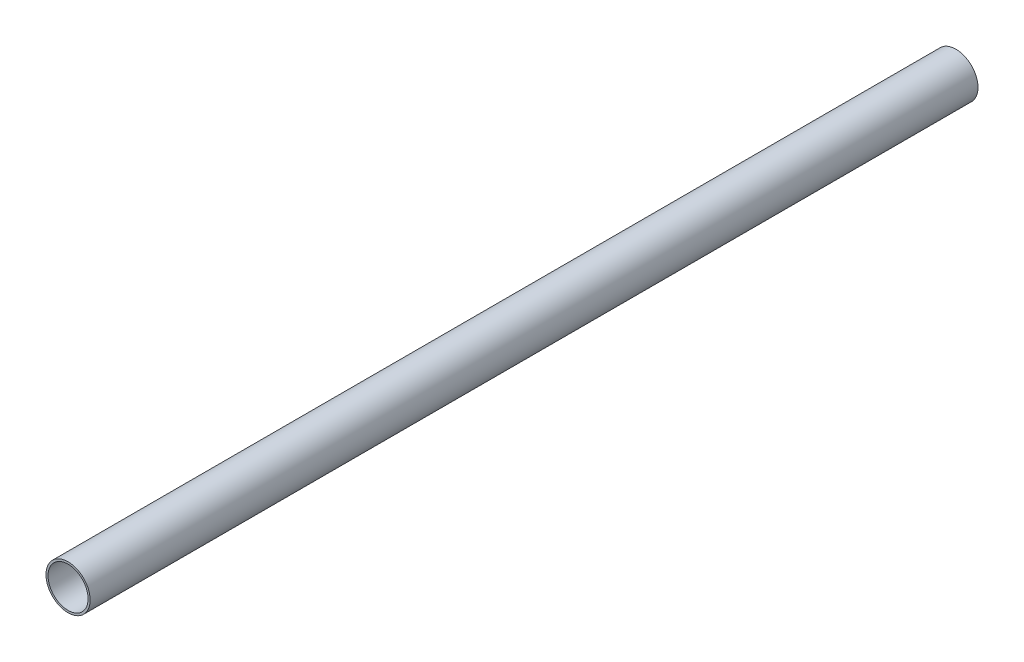
from build123d import *

# Parameters (mm, degrees)
PIPESKETCH_R    = 136.525
PIPESKETCH_R_2  = 123.825
EXTRUSION_DEPTH = 5486.4


with BuildPart() as part:
    # PipeSketch → Extrusion (new body)
    with BuildSketch(Plane.XY):
        Circle(PIPESKETCH_R)
        Circle(PIPESKETCH_R_2, mode=Mode.SUBTRACT)
    extrude(amount=EXTRUSION_DEPTH)


solid = part.part
